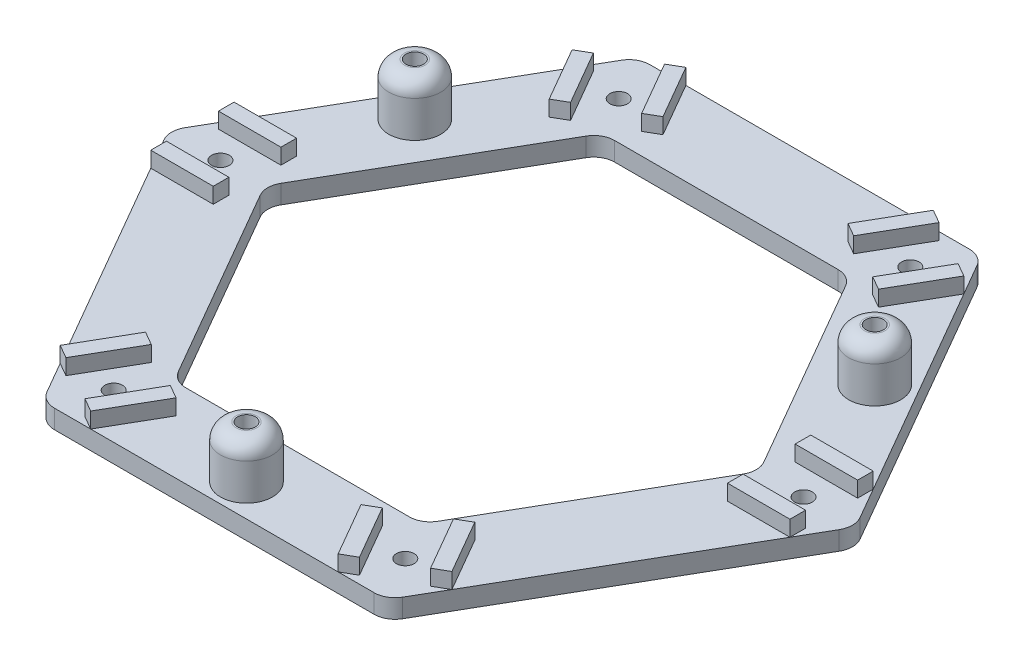
from build123d import *

# Parameters (mm, degrees)
SKETCH1_R           = 0.85
EXTRUDE1_DEPTH      = 1.8
FILLET1_R           = 2
SKETCH3_R           = 2.5
EXTRUDE3_DEPTH      = 5
SKETCH4_R           = 0.85
EXTRUDE4_DEPTH      = 6
EXTRUDE4_DEPTH_BACK = 10
FILLET2_R           = 1.5
SKETCH_1_W          = 6
SKETCH_1_H          = 1.5
EXTRUDE_1_DEPTH     = 1.5


with BuildPart() as part:
    # Sketch1 → Extrude1 (new body)
    with BuildSketch(Plane(origin=(0, 0, 0), x_dir=(1, 0, 0), z_dir=(0, 1, 0))):
        Polygon((33, 0), (16.5, 28.578838325), (-16.5, 28.578838325), (-33, 0), (-16.5, -28.578838325), (16.5, -28.578838325), align=None)
        with Locations(Location((-14, 24.248711306, 0), (0, 0, 270))):  # turned: the seam where the file's is
            Circle(SKETCH1_R, mode=Mode.SUBTRACT)
        with Locations(Location((14, 24.248711306, 0), (0, 0, 270))):  # turned: the seam where the file's is
            Circle(SKETCH1_R, mode=Mode.SUBTRACT)
        with Locations(Location((28, 0, 0), (0, 0, 270))):  # turned: the seam where the file's is
            Circle(SKETCH1_R, mode=Mode.SUBTRACT)
        with Locations(Location((14, -24.248711306, 0), (0, 0, 270))):  # turned: the seam where the file's is
            Circle(SKETCH1_R, mode=Mode.SUBTRACT)
        with Locations(Location((-14, -24.248711306, 0), (0, 0, 270))):  # turned: the seam where the file's is
            Circle(SKETCH1_R, mode=Mode.SUBTRACT)
        with Locations(Location((-28, 0, 0), (0, 0, 270))):  # turned: the seam where the file's is
            Circle(SKETCH1_R, mode=Mode.SUBTRACT)
        Polygon((11.881197846, -20.578838325), (23.762395693, 0), (11.881197846, 20.578838325), (-11.881197846, 20.578838325), (-23.762395693, 0), (-11.881197846, -20.578838325), align=None, mode=Mode.SUBTRACT)
    extrude(amount=EXTRUDE1_DEPTH)

    # Fillet1
    fillet1_edges = [part.edges().sort_by_distance(p)[0] for p in [
        (16.5, 0.9, -28.578838325),
        (33, 0.9, 0),
        (16.5, 0.9, 28.578838325),
        (-16.5, 0.9, 28.578838325),
        (-33, 0.9, 0),
        (-16.5, 0.9, -28.578838325),
        (-23.762395693, 0.9, 0),
        (-11.881197846, 0.9, 20.578838325),
        (11.881197846, 0.9, 20.578838325),
        (23.762395693, 0.9, 0),
        (11.881197846, 0.9, -20.578838325),
        (-11.881197846, 0.9, -20.578838325),
    ]]
    fillet(fillet1_edges, radius=FILLET1_R)

    # Sketch3 → Extrude3 (add)
    with BuildSketch(Plane(origin=(0, 1.8, 0), x_dir=(1, 0, 0), z_dir=(0, 1, 0))):
        with Locations(Location((-22.083647797, 12.75, 0), (0, 0, 270))):  # turned: the seam where the file's is
            Circle(SKETCH3_R)
        with Locations(Location((22.083647797, 12.75, 0), (0, 0, 270))):  # turned: the seam where the file's is
            Circle(SKETCH3_R)
        with Locations(Location((0, -25.5, 0), (0, 0, 270))):  # turned: the seam where the file's is
            Circle(SKETCH3_R)
    extrude(amount=EXTRUDE3_DEPTH)

    # Sketch4 → Extrude4 (cut, two sides)
    with BuildSketch(Plane(origin=(0, 1.8, 0), x_dir=(1, 0, 0), z_dir=(0, 1, 0))) as extrude4_sk:
        with Locations(Location((-22.083647797, 12.75, 0), (0, 0, 270))):  # turned: the seam where the file's is
            Circle(SKETCH4_R)
        with Locations(Location((22.083647797, 12.75, 0), (0, 0, 270))):  # turned: the seam where the file's is
            Circle(SKETCH4_R)
        with Locations(Location((0, -25.5, 0), (0, 0, 270))):  # turned: the seam where the file's is
            Circle(SKETCH4_R)
    extrude(amount=EXTRUDE4_DEPTH, mode=Mode.SUBTRACT)
    extrude(extrude4_sk.sketch, amount=-EXTRUDE4_DEPTH_BACK, mode=Mode.SUBTRACT)

    # Fillet2
    fillet2_edges = [part.edges().sort_by_distance(p)[0] for p in [
        (-22.083647797, 6.8, -15.25),
        (22.083647797, 6.8, -15.25),
        (0, 6.8, 23),
    ]]
    fillet(fillet2_edges, radius=FILLET2_R)

    # 草图1 → 凸台-拉伸1 (add)
    with BuildSketch(Plane(origin=(0, 1.8, 0), x_dir=(1, 0, 0), z_dir=(0, 1, 0))):
        with Locations((-27.690598923, 3.25)):
            Rectangle(SKETCH_1_W, SKETCH_1_H)
        with Locations((-27.690598923, -3.25)):
            Rectangle(SKETCH_1_W, SKETCH_1_H)
        Polygon((-11.881197846, 28.578838325), (-8.881197846, 23.382685902), (-10.180235952, 22.632685902), (-13.180235952, 27.828838325), align=None)
        Polygon((-15.809401077, 19.382685902), (-14.510362971, 20.132685902), (-17.510362971, 25.328838325), (-18.809401077, 24.578838325), align=None)
        Polygon((18.809401077, 24.578838325), (15.809401077, 19.382685902), (14.510362971, 20.132685902), (17.510362971, 25.328838325), align=None)
        Polygon((8.881197846, 23.382685902), (10.180235952, 22.632685902), (13.180235952, 27.828838325), (11.881197846, 28.578838325), align=None)
        with Locations((27.690598923, -3.25)):
            Rectangle(SKETCH_1_W, SKETCH_1_H)
        with Locations((27.690598923, 3.25)):
            Rectangle(SKETCH_1_W, SKETCH_1_H)
        Polygon((11.881197846, -28.578838325), (8.881197846, -23.382685902), (10.180235952, -22.632685902), (13.180235952, -27.828838325), align=None)
        Polygon((15.809401077, -19.382685902), (14.510362971, -20.132685902), (17.510362971, -25.328838325), (18.809401077, -24.578838325), align=None)
        Polygon((-18.809401077, -24.578838325), (-15.809401077, -19.382685902), (-14.510362971, -20.132685902), (-17.510362971, -25.328838325), align=None)
        Polygon((-8.881197846, -23.382685902), (-10.180235952, -22.632685902), (-13.180235952, -27.828838325), (-11.881197846, -28.578838325), align=None)
    extrude(amount=EXTRUDE_1_DEPTH)


solid = part.part
